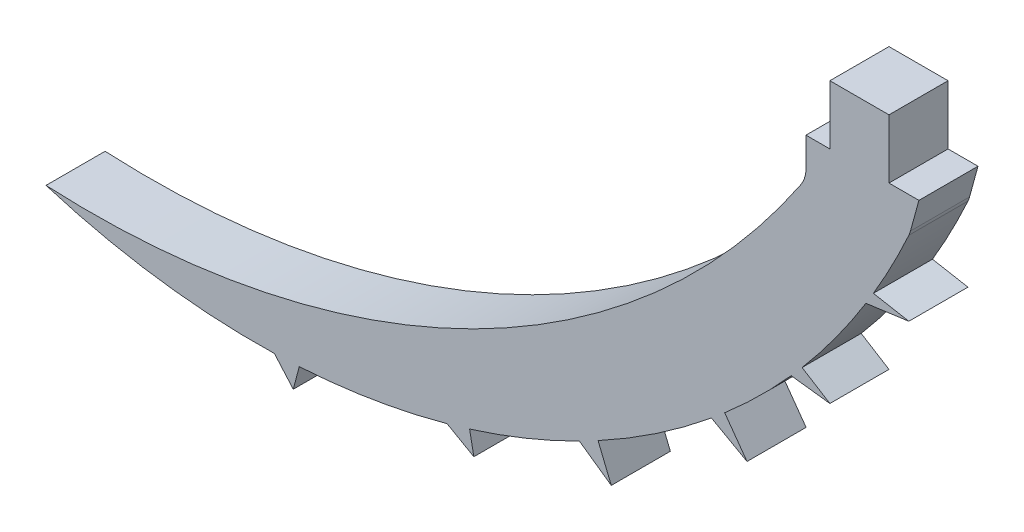
from build123d import *

# Parameters (mm, degrees)
BOSS_EXTRUDE1_DEPTH = 1.524


with BuildPart() as part:
    # Sketch1 → Boss-Extrude1 (new body)
    with BuildSketch(Plane.XY):
        with BuildLine():
            Line((-4.3376529, 0), (-4.3376529, 1.524))
            Line((-4.3376529, 1.524), (-5.8616529, 1.524))
            Line((-5.8616529, 1.524), (-5.8616529, 0))
            Line((-5.8616529, 0), (-6.478290939, 0))
            Line((-6.478290939, 0), (-6.478290939, -0.743115039))
            ThreePointArc((-6.478290939, -0.743115039), (-6.511193249, -0.964611222), (-6.60705881, -1.166979488))
            ThreePointArc((-6.60705881, -1.166979488), (-15.054242265, -8.616097958), (-26.078104852, -10.922334716))
            ThreePointArc((-26.078104852, -10.922334716), (-23.165548821, -11.565461887), (-20.18747251, -11.731764839))
            Line((-20.18747251, -11.731764839), (-19.700670178, -12.287185002))
            Line((-19.700670178, -12.287185002), (-19.547051581, -11.704642596))
            ThreePointArc((-19.547051581, -11.704642596), (-17.624782342, -11.488416043), (-15.735636356, -11.072482882))
            Line((-15.735636356, -11.072482882), (-15.043782744, -11.466191113))
            Line((-15.043782744, -11.466191113), (-15.154372523, -10.901903689))
            ThreePointArc((-15.154372523, -10.901903689), (-13.71444875, -10.38734424), (-12.321981989, -9.755530806))
            Line((-12.321981989, -9.755530806), (-11.499632126, -10.334098846))
            Line((-11.499632126, -10.334098846), (-11.840203527, -9.503461421))
            ThreePointArc((-11.840203527, -9.503461421), (-10.331263681, -8.589737909), (-8.916295851, -7.536335727))
            Line((-8.916295851, -7.536335727), (-7.998857494, -8.049594043))
            Line((-7.998857494, -8.049594043), (-8.574085726, -7.248219572))
            ThreePointArc((-8.574085726, -7.248219572), (-7.68975334, -6.433548021), (-6.860257429, -5.563105582))
            Line((-6.860257429, -5.563105582), (-5.8616529, -5.685853343))
            Line((-5.8616529, -5.685853343), (-6.578924281, -5.240527193))
            ThreePointArc((-6.578924281, -5.240527193), (-5.71334828, -4.14305213), (-4.933175939, -2.983308863))
            Line((-4.933175939, -2.983308863), (-3.82490487, -2.830476181))
            Line((-3.82490487, -2.830476181), (-4.739829013, -2.663849113))
            ThreePointArc((-4.739829013, -2.663849113), (-4.258864728, -1.798680626), (-3.82490487, -0.909005407))
            ThreePointArc((-3.82490487, -0.909005407), (-3.801959849, -0.852730225), (-3.783572445, -0.794805504))
            Line((-3.783572445, -0.794805504), (-3.565751855, 0))
            Line((-3.565751855, 0), (-4.3376529, 0))
        make_face()
    extrude(amount=BOSS_EXTRUDE1_DEPTH)


solid = part.part
